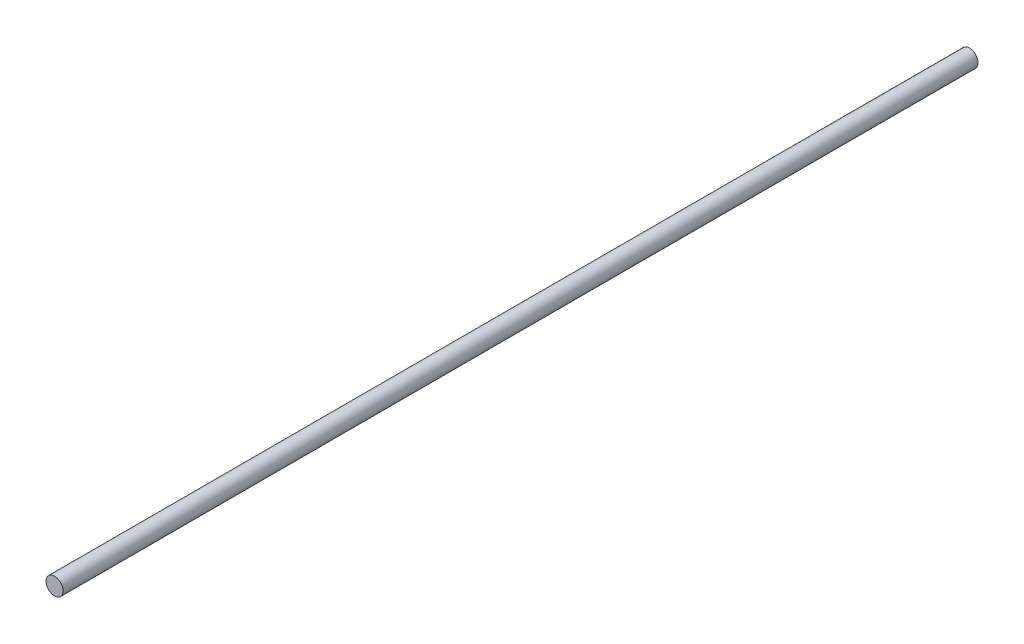
from build123d import *

# Parameters (mm, degrees)
SKETCH1_R           = 3
BOSS_EXTRUDE1_DEPTH = 320


with BuildPart() as part:
    # Sketch1 → Boss-Extrude1 (new body)
    with BuildSketch(Plane.XY):
        Circle(SKETCH1_R)
    extrude(amount=BOSS_EXTRUDE1_DEPTH)


solid = part.part
